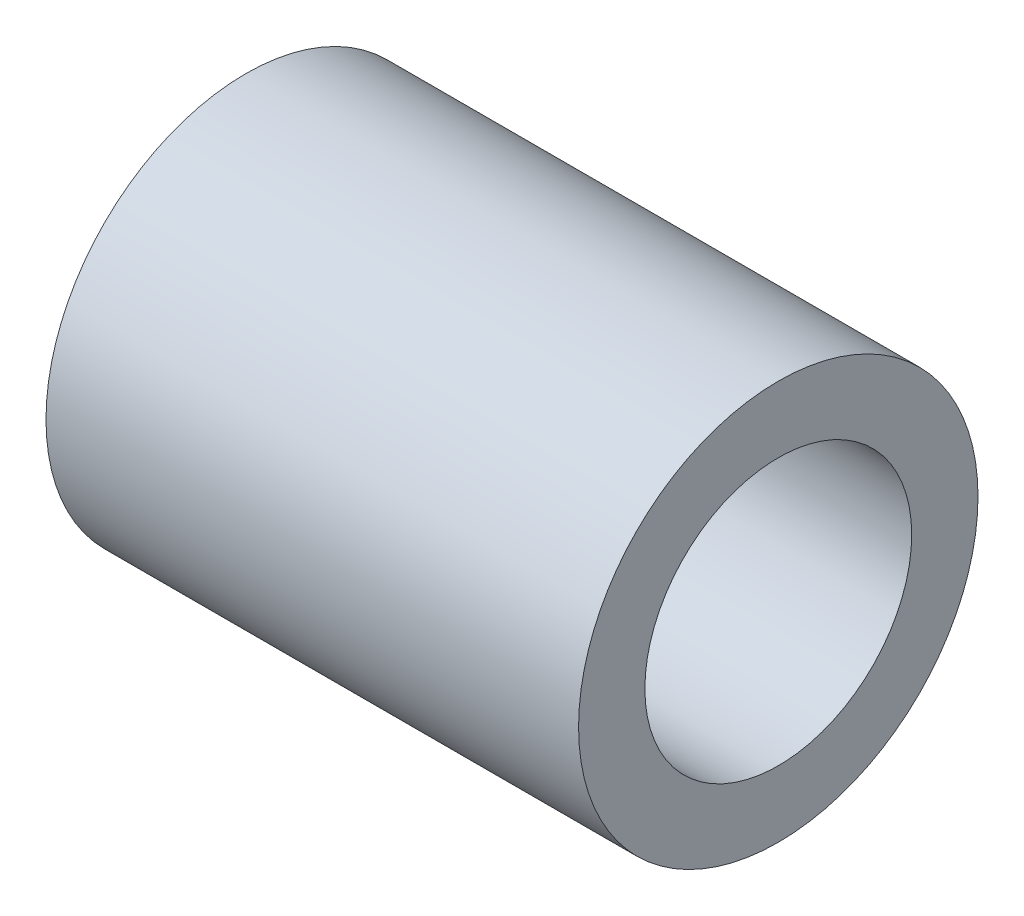
from build123d import *

# Parameters (mm, degrees)
SKETCH1_R           = 9.525
SKETCH1_R_2         = 6.3627
BOSS_EXTRUDE1_DEPTH = 25.4


with BuildPart() as part:
    # Sketch1 → Boss-Extrude1 (new body)
    with BuildSketch(Plane(origin=(0, 0, 0), x_dir=(0, 0, -1), z_dir=(1, 0, 0))):
        Circle(SKETCH1_R)
        Circle(SKETCH1_R_2, mode=Mode.SUBTRACT)
    extrude(amount=BOSS_EXTRUDE1_DEPTH)


solid = part.part
